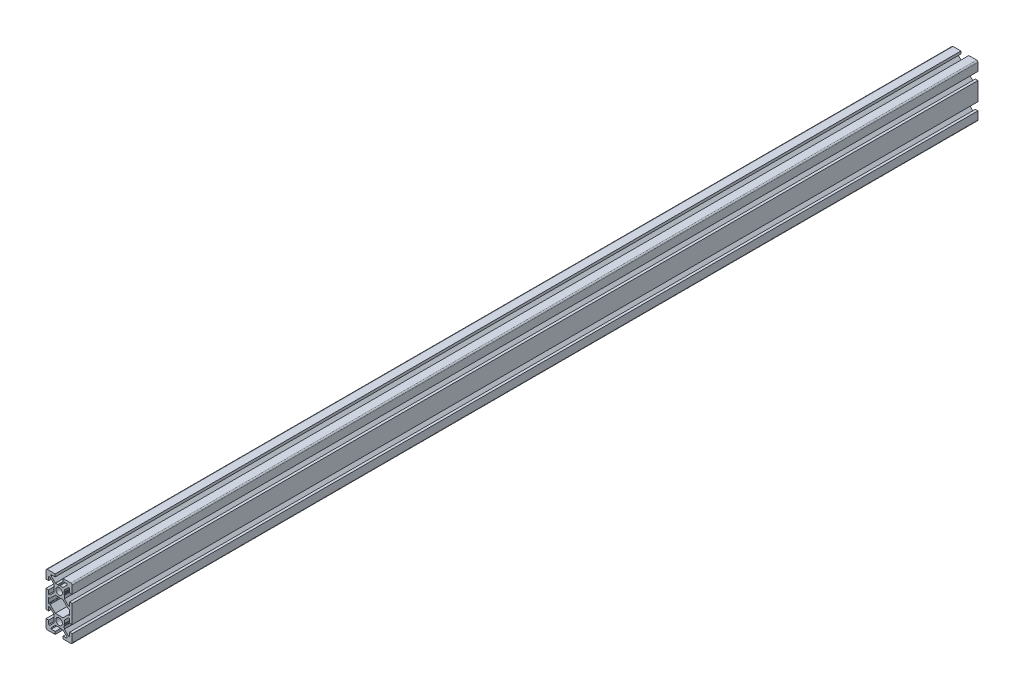
from build123d import *

# Parameters (mm, degrees)
SKETCH1_R           = 2.5
BOSS_EXTRUDE1_DEPTH = 691
SKETCH2_R           = 2
CUT_EXTRUDE1_DEPTH  = 21


with BuildPart() as part:
    # Sketch1 → Boss-Extrude1 (new body)
    with BuildSketch(Plane(origin=(0, 0, -600), x_dir=(-1, 0, 0), z_dir=(0, 0, -1))):
        with BuildLine():
            Line((10, -7), (10, 7))
            Line((10, 7), (8, 7))
            Line((8, 7), (8, 4))
            Line((8, 4), (7.060660172, 4))
            Line((7.060660172, 4), (4, 7.060660172))
            Line((4, 7.060660172), (4, 7.5))
            Line((4, 7.5), (3.750976592, 8.781114371))
            Line((3.750976592, 8.781114371), (3.933012702, 9.096410162))
            ThreePointArc((3.933012702, 9.096410162), (4, 9.346410162), (3.933012702, 9.596410162))
            Line((3.933012702, 9.596410162), (3.7, 10))
            Line((3.7, 10), (3.933012702, 10.403589838))
            ThreePointArc((3.933012702, 10.403589838), (3.982962913, 10.524180316), (4, 10.653589838))
            Line((4, 10.653589838), (4, 12.939339828))
            Line((4, 12.939339828), (7.060660172, 16))
            Line((7.060660172, 16), (8, 16))
            Line((8, 16), (8, 13))
            Line((8, 13), (10, 13))
            Line((10, 13), (10, 19))
            ThreePointArc((10, 19), (9.707106781, 19.707106781), (9, 20))
            Line((9, 20), (3, 20))
            Line((3, 20), (3, 18))
            Line((3, 18), (6, 18))
            Line((6, 18), (6, 17.060660172))
            Line((6, 17.060660172), (2.939339828, 14))
            Line((2.939339828, 14), (2.5, 14))
            Line((2.5, 14), (1.218885629, 13.750976592))
            Line((1.218885629, 13.750976592), (0.903589838, 13.933012702))
            ThreePointArc((0.903589838, 13.933012702), (0.653589838, 14), (0.403589838, 13.933012702))
            Line((0.403589838, 13.933012702), (0, 13.7))
            Line((0, 13.7), (-0.403589838, 13.933012702))
            ThreePointArc((-0.403589838, 13.933012702), (-0.524180316, 13.982962913), (-0.653589838, 14))
            Line((-0.653589838, 14), (-2.939339828, 14))
            Line((-2.939339828, 14), (-6, 17.060660172))
            Line((-6, 17.060660172), (-6, 18))
            Line((-6, 18), (-3, 18))
            Line((-3, 18), (-3, 20))
            Line((-3, 20), (-9, 20))
            ThreePointArc((-9, 20), (-9.707106781, 19.707106781), (-10, 19))
            Line((-10, 19), (-10, 13))
            Line((-10, 13), (-8, 13))
            Line((-8, 13), (-8, 16))
            Line((-8, 16), (-7.060660172, 16))
            Line((-7.060660172, 16), (-4, 12.939339828))
            Line((-4, 12.939339828), (-4, 12.5))
            Line((-4, 12.5), (-3.750976592, 11.218885629))
            Line((-3.750976592, 11.218885629), (-3.933012702, 10.903589838))
            ThreePointArc((-3.933012702, 10.903589838), (-4, 10.653589838), (-3.933012702, 10.403589838))
            Line((-3.933012702, 10.403589838), (-3.7, 10))
            Line((-3.7, 10), (-3.933012702, 9.596410162))
            ThreePointArc((-3.933012702, 9.596410162), (-3.982962913, 9.475819684), (-4, 9.346410162))
            Line((-4, 9.346410162), (-4, 7.060660172))
            Line((-4, 7.060660172), (-7.060660172, 4))
            Line((-7.060660172, 4), (-8, 4))
            Line((-8, 4), (-8, 7))
            Line((-8, 7), (-10, 7))
            Line((-10, 7), (-10, -7))
            Line((-10, -7), (-8, -7))
            Line((-8, -7), (-8, -4))
            Line((-8, -4), (-7.060660172, -4))
            Line((-7.060660172, -4), (-4, -7.060660172))
            Line((-4, -7.060660172), (-4, -9.346410162))
            ThreePointArc((-4, -9.346410162), (-3.982962913, -9.475819684), (-3.933012702, -9.596410162))
            Line((-3.933012702, -9.596410162), (-3.7, -10))
            Line((-3.7, -10), (-3.933012702, -10.403589838))
            ThreePointArc((-3.933012702, -10.403589838), (-4, -10.653589838), (-3.933012702, -10.903589838))
            Line((-3.933012702, -10.903589838), (-3.750976592, -11.218885629))
            Line((-3.750976592, -11.218885629), (-4, -12.5))
            Line((-4, -12.5), (-4, -12.939339828))
            Line((-4, -12.939339828), (-7.060660172, -16))
            Line((-7.060660172, -16), (-8, -16))
            Line((-8, -16), (-8, -13))
            Line((-8, -13), (-10, -13))
            Line((-10, -13), (-10, -19))
            ThreePointArc((-10, -19), (-9.707106781, -19.707106781), (-9, -20))
            Line((-9, -20), (-3, -20))
            Line((-3, -20), (-3, -18))
            Line((-3, -18), (-6, -18))
            Line((-6, -18), (-6, -17.060660172))
            Line((-6, -17.060660172), (-2.939339828, -14))
            Line((-2.939339828, -14), (-0.653589838, -14))
            ThreePointArc((-0.653589838, -14), (-0.524180316, -13.982962913), (-0.403589838, -13.933012702))
            Line((-0.403589838, -13.933012702), (0, -13.7))
            Line((0, -13.7), (0.403589839, -13.933012702))
            ThreePointArc((0.403589839, -13.933012702), (0.653589839, -14), (0.903589838, -13.933012702))
            Line((0.903589838, -13.933012702), (1.218885629, -13.750976592))
            Line((1.218885629, -13.750976592), (2.5, -14))
            Line((2.5, -14), (2.939339828, -14))
            Line((2.939339828, -14), (6, -17.060660172))
            Line((6, -17.060660172), (6, -18))
            Line((6, -18), (3, -18))
            Line((3, -18), (3, -20))
            Line((3, -20), (9, -20))
            ThreePointArc((9, -20), (9.707106781, -19.707106781), (10, -19))
            Line((10, -19), (10, -13))
            Line((10, -13), (8, -13))
            Line((8, -13), (8, -16))
            Line((8, -16), (7.060660172, -16))
            Line((7.060660172, -16), (4, -12.939339828))
            Line((4, -12.939339828), (4, -10.653589838))
            ThreePointArc((4, -10.653589838), (3.982962913, -10.524180316), (3.933012702, -10.403589838))
            Line((3.933012702, -10.403589838), (3.7, -10))
            Line((3.7, -10), (3.933012702, -9.596410162))
            ThreePointArc((3.933012702, -9.596410162), (4, -9.346410162), (3.933012702, -9.096410162))
            Line((3.933012702, -9.096410162), (3.750976592, -8.781114371))
            Line((3.750976592, -8.781114371), (4, -7.5))
            Line((4, -7.5), (4, -7.060660172))
            Line((4, -7.060660172), (7.060660172, -4))
            Line((7.060660172, -4), (8, -4))
            Line((8, -4), (8, -7))
            Line((8, -7), (10, -7))
        make_face()
        with Locations((0, -10)):
            Circle(SKETCH1_R, mode=Mode.SUBTRACT)
        with Locations((0, 10)):
            Circle(SKETCH1_R, mode=Mode.SUBTRACT)
        with BuildLine():
            Line((8, 1.7), (8, -1.7))
            ThreePointArc((8, -1.7), (7.912132034, -1.912132034), (7.7, -2))
            Line((7.7, -2), (7.063603897, -2))
            ThreePointArc((7.063603897, -2), (6.948798867, -2.02283614), (6.851471863, -2.087867966))
            Line((6.851471863, -2.087867966), (2.939339828, -6))
            Line((2.939339828, -6), (-2.939339828, -6))
            Line((-2.939339828, -6), (-6.851471863, -2.087867966))
            ThreePointArc((-6.851471863, -2.087867966), (-6.948798867, -2.02283614), (-7.063603897, -2))
            Line((-7.063603897, -2), (-7.7, -2))
            ThreePointArc((-7.7, -2), (-7.912132034, -1.912132034), (-8, -1.7))
            Line((-8, -1.7), (-8, 1.7))
            ThreePointArc((-8, 1.7), (-7.912132034, 1.912132034), (-7.7, 2))
            Line((-7.7, 2), (-7.063603897, 2))
            ThreePointArc((-7.063603897, 2), (-6.948798867, 2.02283614), (-6.851471863, 2.087867966))
            Line((-6.851471863, 2.087867966), (-2.939339828, 6))
            Line((-2.939339828, 6), (2.939339828, 6))
            Line((2.939339828, 6), (6.851471863, 2.087867966))
            ThreePointArc((6.851471863, 2.087867966), (6.948798867, 2.02283614), (7.063603897, 2))
            Line((7.063603897, 2), (7.7, 2))
            ThreePointArc((7.7, 2), (7.912132034, 1.912132034), (8, 1.7))
        make_face(mode=Mode.SUBTRACT)
    extrude(amount=-BOSS_EXTRUDE1_DEPTH)

    # Sketch2 → Cut-Extrude1 (cut, through all)
    with BuildSketch(Plane.ZY.offset(10)):
        with Locations((81, 10)):
            Circle(SKETCH2_R)
        with Locations((81, -10)):
            Circle(SKETCH2_R)
    cut_extrude1 = extrude(amount=-CUT_EXTRUDE1_DEPTH, mode=Mode.SUBTRACT)

    # Mirror1: Cut-Extrude1 across plane
    add(cut_extrude1.mirror(Plane.XY.offset(-254.5)), mode=Mode.SUBTRACT)


solid = part.part
